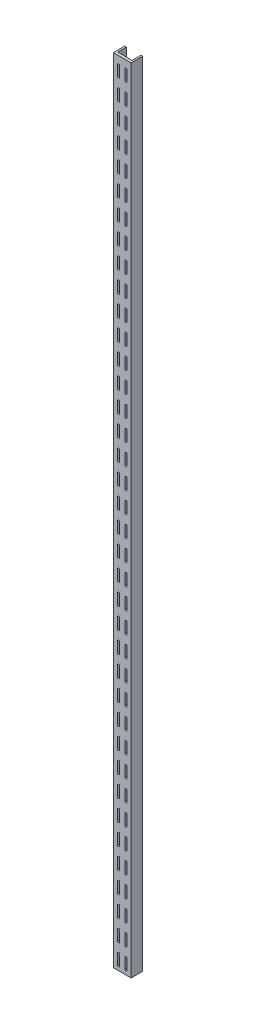
from build123d import *

# Parameters (mm, degrees)
BOSS_EXTRUDE1_DEPTH = 1219.2
CUT_EXTRUDE3_DEPTH  = 5.15


with BuildPart() as part:
    # Sketch1 → Boss-Extrude1 (new body)
    with BuildSketch(Plane(origin=(0, 0, 0), x_dir=(1, 0, 0), z_dir=(0, 1, 0))):
        Polygon((0, 0), (0, 17.7), (2.62, 17.7), (2.62, 4.15), (24.7, 4.15), (24.7, 17.7), (27.32, 17.7), (27.32, 0), align=None)
    extrude(amount=BOSS_EXTRUDE1_DEPTH)

    # Sketch4 → Cut-Extrude3 (cut, through all)
    with BuildSketch(Plane(origin=(0, 0, -4.15), x_dir=(-1, 0, 0), z_dir=(0, 0, -1))):
        with BuildLine():
            Line((-17.9, 1206.81), (-17.9, 1190.81))
            ThreePointArc((-17.9, 1190.81), (-19.4, 1189.31), (-20.9, 1190.81))
            Line((-20.9, 1190.81), (-20.9, 1206.81))
            ThreePointArc((-20.9, 1206.81), (-19.4, 1208.31), (-17.9, 1206.81))
        make_face()
        with BuildLine():
            Line((-20.9, 1174.81), (-20.9, 1158.81))
            ThreePointArc((-20.9, 1158.81), (-19.4, 1157.31), (-17.9, 1158.81))
            Line((-17.9, 1158.81), (-17.9, 1174.81))
            ThreePointArc((-17.9, 1174.81), (-19.4, 1176.31), (-20.9, 1174.81))
        make_face()
        with BuildLine():
            Line((-20.9, 1142.81), (-20.9, 1126.81))
            ThreePointArc((-20.9, 1126.81), (-19.4, 1125.31), (-17.9, 1126.81))
            Line((-17.9, 1126.81), (-17.9, 1142.81))
            ThreePointArc((-17.9, 1142.81), (-19.4, 1144.31), (-20.9, 1142.81))
        make_face()
        with BuildLine():
            Line((-20.9, 1110.81), (-20.9, 1094.81))
            ThreePointArc((-20.9, 1094.81), (-19.4, 1093.31), (-17.9, 1094.81))
            Line((-17.9, 1094.81), (-17.9, 1110.81))
            ThreePointArc((-17.9, 1110.81), (-19.4, 1112.31), (-20.9, 1110.81))
        make_face()
        with BuildLine():
            Line((-20.9, 1078.81), (-20.9, 1062.81))
            ThreePointArc((-20.9, 1062.81), (-19.4, 1061.31), (-17.9, 1062.81))
            Line((-17.9, 1062.81), (-17.9, 1078.81))
            ThreePointArc((-17.9, 1078.81), (-19.4, 1080.31), (-20.9, 1078.81))
        make_face()
        with BuildLine():
            Line((-20.9, 1046.81), (-20.9, 1030.81))
            ThreePointArc((-20.9, 1030.81), (-19.4, 1029.31), (-17.9, 1030.81))
            Line((-17.9, 1030.81), (-17.9, 1046.81))
            ThreePointArc((-17.9, 1046.81), (-19.4, 1048.31), (-20.9, 1046.81))
        make_face()
        with BuildLine():
            Line((-20.9, 1014.81), (-20.9, 998.81))
            ThreePointArc((-20.9, 998.81), (-19.4, 997.31), (-17.9, 998.81))
            Line((-17.9, 998.81), (-17.9, 1014.81))
            ThreePointArc((-17.9, 1014.81), (-19.4, 1016.31), (-20.9, 1014.81))
        make_face()
        with BuildLine():
            Line((-20.9, 982.81), (-20.9, 966.81))
            ThreePointArc((-20.9, 966.81), (-19.4, 965.31), (-17.9, 966.81))
            Line((-17.9, 966.81), (-17.9, 982.81))
            ThreePointArc((-17.9, 982.81), (-19.4, 984.31), (-20.9, 982.81))
        make_face()
        with BuildLine():
            Line((-20.9, 950.81), (-20.9, 934.81))
            ThreePointArc((-20.9, 934.81), (-19.4, 933.31), (-17.9, 934.81))
            Line((-17.9, 934.81), (-17.9, 950.81))
            ThreePointArc((-17.9, 950.81), (-19.4, 952.31), (-20.9, 950.81))
        make_face()
        with BuildLine():
            Line((-20.9, 918.81), (-20.9, 902.81))
            ThreePointArc((-20.9, 902.81), (-19.4, 901.31), (-17.9, 902.81))
            Line((-17.9, 902.81), (-17.9, 918.81))
            ThreePointArc((-17.9, 918.81), (-19.4, 920.31), (-20.9, 918.81))
        make_face()
        with BuildLine():
            Line((-20.9, 886.81), (-20.9, 870.81))
            ThreePointArc((-20.9, 870.81), (-19.4, 869.31), (-17.9, 870.81))
            Line((-17.9, 870.81), (-17.9, 886.81))
            ThreePointArc((-17.9, 886.81), (-19.4, 888.31), (-20.9, 886.81))
        make_face()
        with BuildLine():
            Line((-20.9, 854.81), (-20.9, 838.81))
            ThreePointArc((-20.9, 838.81), (-19.4, 837.31), (-17.9, 838.81))
            Line((-17.9, 838.81), (-17.9, 854.81))
            ThreePointArc((-17.9, 854.81), (-19.4, 856.31), (-20.9, 854.81))
        make_face()
        with BuildLine():
            Line((-20.9, 822.81), (-20.9, 806.81))
            ThreePointArc((-20.9, 806.81), (-19.4, 805.31), (-17.9, 806.81))
            Line((-17.9, 806.81), (-17.9, 822.81))
            ThreePointArc((-17.9, 822.81), (-19.4, 824.31), (-20.9, 822.81))
        make_face()
        with BuildLine():
            Line((-20.9, 790.81), (-20.9, 774.81))
            ThreePointArc((-20.9, 774.81), (-19.4, 773.31), (-17.9, 774.81))
            Line((-17.9, 774.81), (-17.9, 790.81))
            ThreePointArc((-17.9, 790.81), (-19.4, 792.31), (-20.9, 790.81))
        make_face()
        with BuildLine():
            Line((-20.9, 758.81), (-20.9, 742.81))
            ThreePointArc((-20.9, 742.81), (-19.4, 741.31), (-17.9, 742.81))
            Line((-17.9, 742.81), (-17.9, 758.81))
            ThreePointArc((-17.9, 758.81), (-19.4, 760.31), (-20.9, 758.81))
        make_face()
        with BuildLine():
            Line((-20.9, 726.81), (-20.9, 710.81))
            ThreePointArc((-20.9, 710.81), (-19.4, 709.31), (-17.9, 710.81))
            Line((-17.9, 710.81), (-17.9, 726.81))
            ThreePointArc((-17.9, 726.81), (-19.4, 728.31), (-20.9, 726.81))
        make_face()
        with BuildLine():
            Line((-20.9, 694.81), (-20.9, 678.81))
            ThreePointArc((-20.9, 678.81), (-19.4, 677.31), (-17.9, 678.81))
            Line((-17.9, 678.81), (-17.9, 694.81))
            ThreePointArc((-17.9, 694.81), (-19.4, 696.31), (-20.9, 694.81))
        make_face()
        with BuildLine():
            Line((-20.9, 662.81), (-20.9, 646.81))
            ThreePointArc((-20.9, 646.81), (-19.4, 645.31), (-17.9, 646.81))
            Line((-17.9, 646.81), (-17.9, 662.81))
            ThreePointArc((-17.9, 662.81), (-19.4, 664.31), (-20.9, 662.81))
        make_face()
        with BuildLine():
            Line((-20.9, 630.81), (-20.9, 614.81))
            ThreePointArc((-20.9, 614.81), (-19.4, 613.31), (-17.9, 614.81))
            Line((-17.9, 614.81), (-17.9, 630.81))
            ThreePointArc((-17.9, 630.81), (-19.4, 632.31), (-20.9, 630.81))
        make_face()
        with BuildLine():
            Line((-20.9, 598.81), (-20.9, 582.81))
            ThreePointArc((-20.9, 582.81), (-19.4, 581.31), (-17.9, 582.81))
            Line((-17.9, 582.81), (-17.9, 598.81))
            ThreePointArc((-17.9, 598.81), (-19.4, 600.31), (-20.9, 598.81))
        make_face()
        with BuildLine():
            Line((-20.9, 566.81), (-20.9, 550.81))
            ThreePointArc((-20.9, 550.81), (-19.4, 549.31), (-17.9, 550.81))
            Line((-17.9, 550.81), (-17.9, 566.81))
            ThreePointArc((-17.9, 566.81), (-19.4, 568.31), (-20.9, 566.81))
        make_face()
        with BuildLine():
            Line((-20.9, 534.81), (-20.9, 518.81))
            ThreePointArc((-20.9, 518.81), (-19.4, 517.31), (-17.9, 518.81))
            Line((-17.9, 518.81), (-17.9, 534.81))
            ThreePointArc((-17.9, 534.81), (-19.4, 536.31), (-20.9, 534.81))
        make_face()
        with BuildLine():
            Line((-20.9, 502.81), (-20.9, 486.81))
            ThreePointArc((-20.9, 486.81), (-19.4, 485.31), (-17.9, 486.81))
            Line((-17.9, 486.81), (-17.9, 502.81))
            ThreePointArc((-17.9, 502.81), (-19.4, 504.31), (-20.9, 502.81))
        make_face()
        with BuildLine():
            Line((-20.9, 470.81), (-20.9, 454.81))
            ThreePointArc((-20.9, 454.81), (-19.4, 453.31), (-17.9, 454.81))
            Line((-17.9, 454.81), (-17.9, 470.81))
            ThreePointArc((-17.9, 470.81), (-19.4, 472.31), (-20.9, 470.81))
        make_face()
        with BuildLine():
            Line((-20.9, 438.81), (-20.9, 422.81))
            ThreePointArc((-20.9, 422.81), (-19.4, 421.31), (-17.9, 422.81))
            Line((-17.9, 422.81), (-17.9, 438.81))
            ThreePointArc((-17.9, 438.81), (-19.4, 440.31), (-20.9, 438.81))
        make_face()
        with BuildLine():
            Line((-20.9, 406.81), (-20.9, 390.81))
            ThreePointArc((-20.9, 390.81), (-19.4, 389.31), (-17.9, 390.81))
            Line((-17.9, 390.81), (-17.9, 406.81))
            ThreePointArc((-17.9, 406.81), (-19.4, 408.31), (-20.9, 406.81))
        make_face()
        with BuildLine():
            Line((-20.9, 374.81), (-20.9, 358.81))
            ThreePointArc((-20.9, 358.81), (-19.4, 357.31), (-17.9, 358.81))
            Line((-17.9, 358.81), (-17.9, 374.81))
            ThreePointArc((-17.9, 374.81), (-19.4, 376.31), (-20.9, 374.81))
        make_face()
        with BuildLine():
            Line((-20.9, 342.81), (-20.9, 326.81))
            ThreePointArc((-20.9, 326.81), (-19.4, 325.31), (-17.9, 326.81))
            Line((-17.9, 326.81), (-17.9, 342.81))
            ThreePointArc((-17.9, 342.81), (-19.4, 344.31), (-20.9, 342.81))
        make_face()
        with BuildLine():
            Line((-20.9, 310.81), (-20.9, 294.81))
            ThreePointArc((-20.9, 294.81), (-19.4, 293.31), (-17.9, 294.81))
            Line((-17.9, 294.81), (-17.9, 310.81))
            ThreePointArc((-17.9, 310.81), (-19.4, 312.31), (-20.9, 310.81))
        make_face()
        with BuildLine():
            Line((-20.9, 278.81), (-20.9, 262.81))
            ThreePointArc((-20.9, 262.81), (-19.4, 261.31), (-17.9, 262.81))
            Line((-17.9, 262.81), (-17.9, 278.81))
            ThreePointArc((-17.9, 278.81), (-19.4, 280.31), (-20.9, 278.81))
        make_face()
        with BuildLine():
            Line((-20.9, 246.81), (-20.9, 230.81))
            ThreePointArc((-20.9, 230.81), (-19.4, 229.31), (-17.9, 230.81))
            Line((-17.9, 230.81), (-17.9, 246.81))
            ThreePointArc((-17.9, 246.81), (-19.4, 248.31), (-20.9, 246.81))
        make_face()
        with BuildLine():
            Line((-20.9, 214.81), (-20.9, 198.81))
            ThreePointArc((-20.9, 198.81), (-19.4, 197.31), (-17.9, 198.81))
            Line((-17.9, 198.81), (-17.9, 214.81))
            ThreePointArc((-17.9, 214.81), (-19.4, 216.31), (-20.9, 214.81))
        make_face()
        with BuildLine():
            Line((-20.9, 182.81), (-20.9, 166.81))
            ThreePointArc((-20.9, 166.81), (-19.4, 165.31), (-17.9, 166.81))
            Line((-17.9, 166.81), (-17.9, 182.81))
            ThreePointArc((-17.9, 182.81), (-19.4, 184.31), (-20.9, 182.81))
        make_face()
        with BuildLine():
            Line((-20.9, 150.81), (-20.9, 134.81))
            ThreePointArc((-20.9, 134.81), (-19.4, 133.31), (-17.9, 134.81))
            Line((-17.9, 134.81), (-17.9, 150.81))
            ThreePointArc((-17.9, 150.81), (-19.4, 152.31), (-20.9, 150.81))
        make_face()
        with BuildLine():
            Line((-20.9, 118.81), (-20.9, 102.81))
            ThreePointArc((-20.9, 102.81), (-19.4, 101.31), (-17.9, 102.81))
            Line((-17.9, 102.81), (-17.9, 118.81))
            ThreePointArc((-17.9, 118.81), (-19.4, 120.31), (-20.9, 118.81))
        make_face()
        with BuildLine():
            Line((-20.9, 86.81), (-20.9, 70.81))
            ThreePointArc((-20.9, 70.81), (-19.4, 69.31), (-17.9, 70.81))
            Line((-17.9, 70.81), (-17.9, 86.81))
            ThreePointArc((-17.9, 86.81), (-19.4, 88.31), (-20.9, 86.81))
        make_face()
        with BuildLine():
            Line((-20.9, 54.81), (-20.9, 38.81))
            ThreePointArc((-20.9, 38.81), (-19.4, 37.31), (-17.9, 38.81))
            Line((-17.9, 38.81), (-17.9, 54.81))
            ThreePointArc((-17.9, 54.81), (-19.4, 56.31), (-20.9, 54.81))
        make_face()
        with BuildLine():
            Line((-20.9, 22.81), (-20.9, 6.81))
            ThreePointArc((-20.9, 6.81), (-19.4, 5.31), (-17.9, 6.81))
            Line((-17.9, 6.81), (-17.9, 22.81))
            ThreePointArc((-17.9, 22.81), (-19.4, 24.31), (-20.9, 22.81))
        make_face()
        with BuildLine():
            Line((-9.42, 758.81), (-9.42, 742.81))
            ThreePointArc((-9.42, 742.81), (-7.92, 741.31), (-6.42, 742.81))
            Line((-6.42, 742.81), (-6.42, 758.81))
            ThreePointArc((-6.42, 758.81), (-7.92, 760.31), (-9.42, 758.81))
        make_face()
        with BuildLine():
            Line((-9.42, 790.81), (-9.42, 774.81))
            ThreePointArc((-9.42, 774.81), (-7.92, 773.31), (-6.42, 774.81))
            Line((-6.42, 774.81), (-6.42, 790.81))
            ThreePointArc((-6.42, 790.81), (-7.92, 792.31), (-9.42, 790.81))
        make_face()
        with BuildLine():
            Line((-9.42, 822.81), (-9.42, 806.81))
            ThreePointArc((-9.42, 806.81), (-7.92, 805.31), (-6.42, 806.81))
            Line((-6.42, 806.81), (-6.42, 822.81))
            ThreePointArc((-6.42, 822.81), (-7.92, 824.31), (-9.42, 822.81))
        make_face()
        with BuildLine():
            Line((-9.42, 854.81), (-9.42, 838.81))
            ThreePointArc((-9.42, 838.81), (-7.92, 837.31), (-6.42, 838.81))
            Line((-6.42, 838.81), (-6.42, 854.81))
            ThreePointArc((-6.42, 854.81), (-7.92, 856.31), (-9.42, 854.81))
        make_face()
        with BuildLine():
            Line((-9.42, 886.81), (-9.42, 870.81))
            ThreePointArc((-9.42, 870.81), (-7.92, 869.31), (-6.42, 870.81))
            Line((-6.42, 870.81), (-6.42, 886.81))
            ThreePointArc((-6.42, 886.81), (-7.92, 888.31), (-9.42, 886.81))
        make_face()
        with BuildLine():
            Line((-9.42, 918.81), (-9.42, 902.81))
            ThreePointArc((-9.42, 902.81), (-7.92, 901.31), (-6.42, 902.81))
            Line((-6.42, 902.81), (-6.42, 918.81))
            ThreePointArc((-6.42, 918.81), (-7.92, 920.31), (-9.42, 918.81))
        make_face()
        with BuildLine():
            Line((-9.42, 950.81), (-9.42, 934.81))
            ThreePointArc((-9.42, 934.81), (-7.92, 933.31), (-6.42, 934.81))
            Line((-6.42, 934.81), (-6.42, 950.81))
            ThreePointArc((-6.42, 950.81), (-7.92, 952.31), (-9.42, 950.81))
        make_face()
        with BuildLine():
            Line((-9.42, 982.81), (-9.42, 966.81))
            ThreePointArc((-9.42, 966.81), (-7.92, 965.31), (-6.42, 966.81))
            Line((-6.42, 966.81), (-6.42, 982.81))
            ThreePointArc((-6.42, 982.81), (-7.92, 984.31), (-9.42, 982.81))
        make_face()
        with BuildLine():
            Line((-9.42, 1014.81), (-9.42, 998.81))
            ThreePointArc((-9.42, 998.81), (-7.92, 997.31), (-6.42, 998.81))
            Line((-6.42, 998.81), (-6.42, 1014.81))
            ThreePointArc((-6.42, 1014.81), (-7.92, 1016.31), (-9.42, 1014.81))
        make_face()
        with BuildLine():
            Line((-9.42, 1046.81), (-9.42, 1030.81))
            ThreePointArc((-9.42, 1030.81), (-7.92, 1029.31), (-6.42, 1030.81))
            Line((-6.42, 1030.81), (-6.42, 1046.81))
            ThreePointArc((-6.42, 1046.81), (-7.92, 1048.31), (-9.42, 1046.81))
        make_face()
        with BuildLine():
            Line((-9.42, 1078.81), (-9.42, 1062.81))
            ThreePointArc((-9.42, 1062.81), (-7.92, 1061.31), (-6.42, 1062.81))
            Line((-6.42, 1062.81), (-6.42, 1078.81))
            ThreePointArc((-6.42, 1078.81), (-7.92, 1080.31), (-9.42, 1078.81))
        make_face()
        with BuildLine():
            Line((-9.42, 1110.81), (-9.42, 1094.81))
            ThreePointArc((-9.42, 1094.81), (-7.92, 1093.31), (-6.42, 1094.81))
            Line((-6.42, 1094.81), (-6.42, 1110.81))
            ThreePointArc((-6.42, 1110.81), (-7.92, 1112.31), (-9.42, 1110.81))
        make_face()
        with BuildLine():
            Line((-9.42, 1142.81), (-9.42, 1126.81))
            ThreePointArc((-9.42, 1126.81), (-7.92, 1125.31), (-6.42, 1126.81))
            Line((-6.42, 1126.81), (-6.42, 1142.81))
            ThreePointArc((-6.42, 1142.81), (-7.92, 1144.31), (-9.42, 1142.81))
        make_face()
        with BuildLine():
            Line((-9.42, 1174.81), (-9.42, 1158.81))
            ThreePointArc((-9.42, 1158.81), (-7.92, 1157.31), (-6.42, 1158.81))
            Line((-6.42, 1158.81), (-6.42, 1174.81))
            ThreePointArc((-6.42, 1174.81), (-7.92, 1176.31), (-9.42, 1174.81))
        make_face()
        with BuildLine():
            Line((-9.42, 1206.81), (-9.42, 1190.81))
            ThreePointArc((-9.42, 1190.81), (-7.92, 1189.31), (-6.42, 1190.81))
            Line((-6.42, 1190.81), (-6.42, 1206.81))
            ThreePointArc((-6.42, 1206.81), (-7.92, 1208.31), (-9.42, 1206.81))
        make_face()
        with BuildLine():
            Line((-9.42, 406.81), (-9.42, 390.81))
            ThreePointArc((-9.42, 390.81), (-7.92, 389.31), (-6.42, 390.81))
            Line((-6.42, 390.81), (-6.42, 406.81))
            ThreePointArc((-6.42, 406.81), (-7.92, 408.31), (-9.42, 406.81))
        make_face()
        with BuildLine():
            Line((-9.42, 438.81), (-9.42, 422.81))
            ThreePointArc((-9.42, 422.81), (-7.92, 421.31), (-6.42, 422.81))
            Line((-6.42, 422.81), (-6.42, 438.81))
            ThreePointArc((-6.42, 438.81), (-7.92, 440.31), (-9.42, 438.81))
        make_face()
        with BuildLine():
            Line((-9.42, 470.81), (-9.42, 454.81))
            ThreePointArc((-9.42, 454.81), (-7.92, 453.31), (-6.42, 454.81))
            Line((-6.42, 454.81), (-6.42, 470.81))
            ThreePointArc((-6.42, 470.81), (-7.92, 472.31), (-9.42, 470.81))
        make_face()
        with BuildLine():
            Line((-9.42, 502.81), (-9.42, 486.81))
            ThreePointArc((-9.42, 486.81), (-7.92, 485.31), (-6.42, 486.81))
            Line((-6.42, 486.81), (-6.42, 502.81))
            ThreePointArc((-6.42, 502.81), (-7.92, 504.31), (-9.42, 502.81))
        make_face()
        with BuildLine():
            Line((-9.42, 534.81), (-9.42, 518.81))
            ThreePointArc((-9.42, 518.81), (-7.92, 517.31), (-6.42, 518.81))
            Line((-6.42, 518.81), (-6.42, 534.81))
            ThreePointArc((-6.42, 534.81), (-7.92, 536.31), (-9.42, 534.81))
        make_face()
        with BuildLine():
            Line((-9.42, 566.81), (-9.42, 550.81))
            ThreePointArc((-9.42, 550.81), (-7.92, 549.31), (-6.42, 550.81))
            Line((-6.42, 550.81), (-6.42, 566.81))
            ThreePointArc((-6.42, 566.81), (-7.92, 568.31), (-9.42, 566.81))
        make_face()
        with BuildLine():
            Line((-9.42, 598.81), (-9.42, 582.81))
            ThreePointArc((-9.42, 582.81), (-7.92, 581.31), (-6.42, 582.81))
            Line((-6.42, 582.81), (-6.42, 598.81))
            ThreePointArc((-6.42, 598.81), (-7.92, 600.31), (-9.42, 598.81))
        make_face()
        with BuildLine():
            Line((-9.42, 630.81), (-9.42, 614.81))
            ThreePointArc((-9.42, 614.81), (-7.92, 613.31), (-6.42, 614.81))
            Line((-6.42, 614.81), (-6.42, 630.81))
            ThreePointArc((-6.42, 630.81), (-7.92, 632.31), (-9.42, 630.81))
        make_face()
        with BuildLine():
            Line((-9.42, 662.81), (-9.42, 646.81))
            ThreePointArc((-9.42, 646.81), (-7.92, 645.31), (-6.42, 646.81))
            Line((-6.42, 646.81), (-6.42, 662.81))
            ThreePointArc((-6.42, 662.81), (-7.92, 664.31), (-9.42, 662.81))
        make_face()
        with BuildLine():
            Line((-9.42, 694.81), (-9.42, 678.81))
            ThreePointArc((-9.42, 678.81), (-7.92, 677.31), (-6.42, 678.81))
            Line((-6.42, 678.81), (-6.42, 694.81))
            ThreePointArc((-6.42, 694.81), (-7.92, 696.31), (-9.42, 694.81))
        make_face()
        with BuildLine():
            Line((-9.42, 726.81), (-9.42, 710.81))
            ThreePointArc((-9.42, 710.81), (-7.92, 709.31), (-6.42, 710.81))
            Line((-6.42, 710.81), (-6.42, 726.81))
            ThreePointArc((-6.42, 726.81), (-7.92, 728.31), (-9.42, 726.81))
        make_face()
        with BuildLine():
            Line((-9.42, 374.81), (-9.42, 358.81))
            ThreePointArc((-9.42, 358.81), (-7.92, 357.31), (-6.42, 358.81))
            Line((-6.42, 358.81), (-6.42, 374.81))
            ThreePointArc((-6.42, 374.81), (-7.92, 376.31), (-9.42, 374.81))
        make_face()
        with BuildLine():
            Line((-9.42, 342.81), (-9.42, 326.81))
            ThreePointArc((-9.42, 326.81), (-7.92, 325.31), (-6.42, 326.81))
            Line((-6.42, 326.81), (-6.42, 342.81))
            ThreePointArc((-6.42, 342.81), (-7.92, 344.31), (-9.42, 342.81))
        make_face()
        with BuildLine():
            Line((-9.42, 310.81), (-9.42, 294.81))
            ThreePointArc((-9.42, 294.81), (-7.92, 293.31), (-6.42, 294.81))
            Line((-6.42, 294.81), (-6.42, 310.81))
            ThreePointArc((-6.42, 310.81), (-7.92, 312.31), (-9.42, 310.81))
        make_face()
        with BuildLine():
            Line((-9.42, 278.81), (-9.42, 262.81))
            ThreePointArc((-9.42, 262.81), (-7.92, 261.31), (-6.42, 262.81))
            Line((-6.42, 262.81), (-6.42, 278.81))
            ThreePointArc((-6.42, 278.81), (-7.92, 280.31), (-9.42, 278.81))
        make_face()
        with BuildLine():
            Line((-9.42, 246.81), (-9.42, 230.81))
            ThreePointArc((-9.42, 230.81), (-7.92, 229.31), (-6.42, 230.81))
            Line((-6.42, 230.81), (-6.42, 246.81))
            ThreePointArc((-6.42, 246.81), (-7.92, 248.31), (-9.42, 246.81))
        make_face()
        with BuildLine():
            Line((-9.42, 214.81), (-9.42, 198.81))
            ThreePointArc((-9.42, 198.81), (-7.92, 197.31), (-6.42, 198.81))
            Line((-6.42, 198.81), (-6.42, 214.81))
            ThreePointArc((-6.42, 214.81), (-7.92, 216.31), (-9.42, 214.81))
        make_face()
        with BuildLine():
            Line((-9.42, 182.81), (-9.42, 166.81))
            ThreePointArc((-9.42, 166.81), (-7.92, 165.31), (-6.42, 166.81))
            Line((-6.42, 166.81), (-6.42, 182.81))
            ThreePointArc((-6.42, 182.81), (-7.92, 184.31), (-9.42, 182.81))
        make_face()
        with BuildLine():
            Line((-9.42, 150.81), (-9.42, 134.81))
            ThreePointArc((-9.42, 134.81), (-7.92, 133.31), (-6.42, 134.81))
            Line((-6.42, 134.81), (-6.42, 150.81))
            ThreePointArc((-6.42, 150.81), (-7.92, 152.31), (-9.42, 150.81))
        make_face()
        with BuildLine():
            Line((-9.42, 118.81), (-9.42, 102.81))
            ThreePointArc((-9.42, 102.81), (-7.92, 101.31), (-6.42, 102.81))
            Line((-6.42, 102.81), (-6.42, 118.81))
            ThreePointArc((-6.42, 118.81), (-7.92, 120.31), (-9.42, 118.81))
        make_face()
        with BuildLine():
            Line((-9.42, 86.81), (-9.42, 70.81))
            ThreePointArc((-9.42, 70.81), (-7.92, 69.31), (-6.42, 70.81))
            Line((-6.42, 70.81), (-6.42, 86.81))
            ThreePointArc((-6.42, 86.81), (-7.92, 88.31), (-9.42, 86.81))
        make_face()
        with BuildLine():
            Line((-9.42, 54.81), (-9.42, 38.81))
            ThreePointArc((-9.42, 38.81), (-7.92, 37.31), (-6.42, 38.81))
            Line((-6.42, 38.81), (-6.42, 54.81))
            ThreePointArc((-6.42, 54.81), (-7.92, 56.31), (-9.42, 54.81))
        make_face()
        with BuildLine():
            Line((-9.42, 22.81), (-9.42, 6.81))
            ThreePointArc((-9.42, 6.81), (-7.92, 5.31), (-6.42, 6.81))
            Line((-6.42, 6.81), (-6.42, 22.81))
            ThreePointArc((-6.42, 22.81), (-7.92, 24.31), (-9.42, 22.81))
        make_face()
    extrude(amount=-CUT_EXTRUDE3_DEPTH, mode=Mode.SUBTRACT)


solid = part.part
